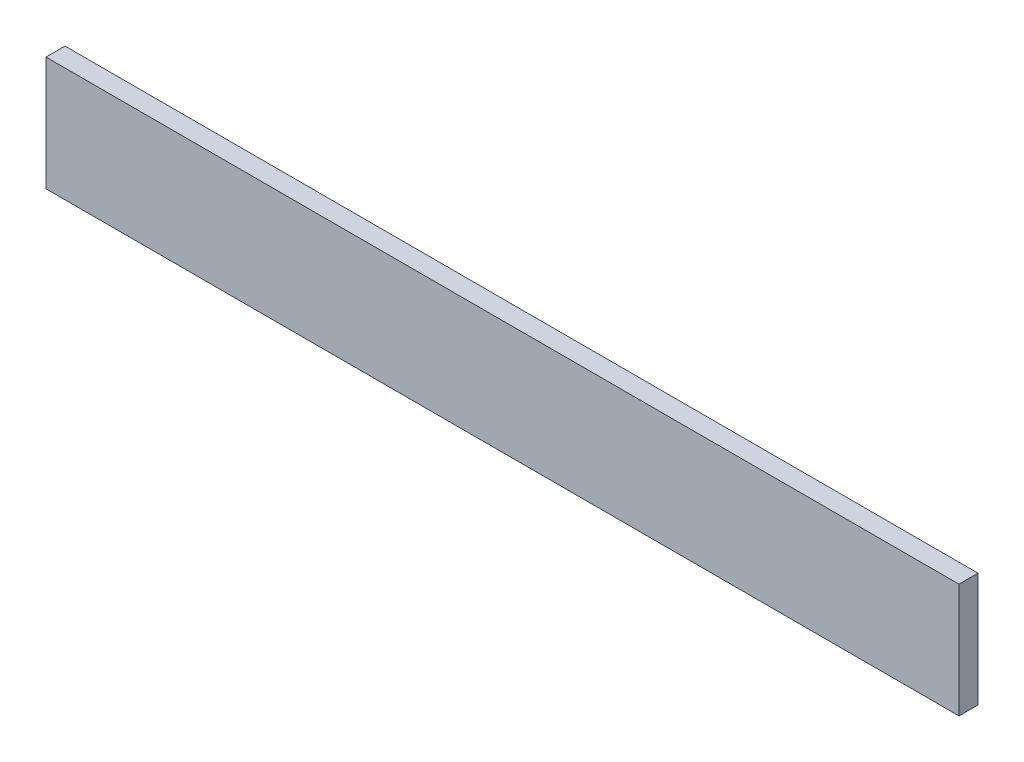
from build123d import *

# Parameters (mm, degrees)
SKETCH1_W           = 304.8
SKETCH1_H           = 38.1
BOSS_EXTRUDE1_DEPTH = 6.35


with BuildPart() as part:
    # Sketch1 → Boss-Extrude1 (new body)
    with BuildSketch(Plane.XY):
        with Locations((152.4, 19.05)):
            Rectangle(SKETCH1_W, SKETCH1_H)
    extrude(amount=BOSS_EXTRUDE1_DEPTH)


solid = part.part
